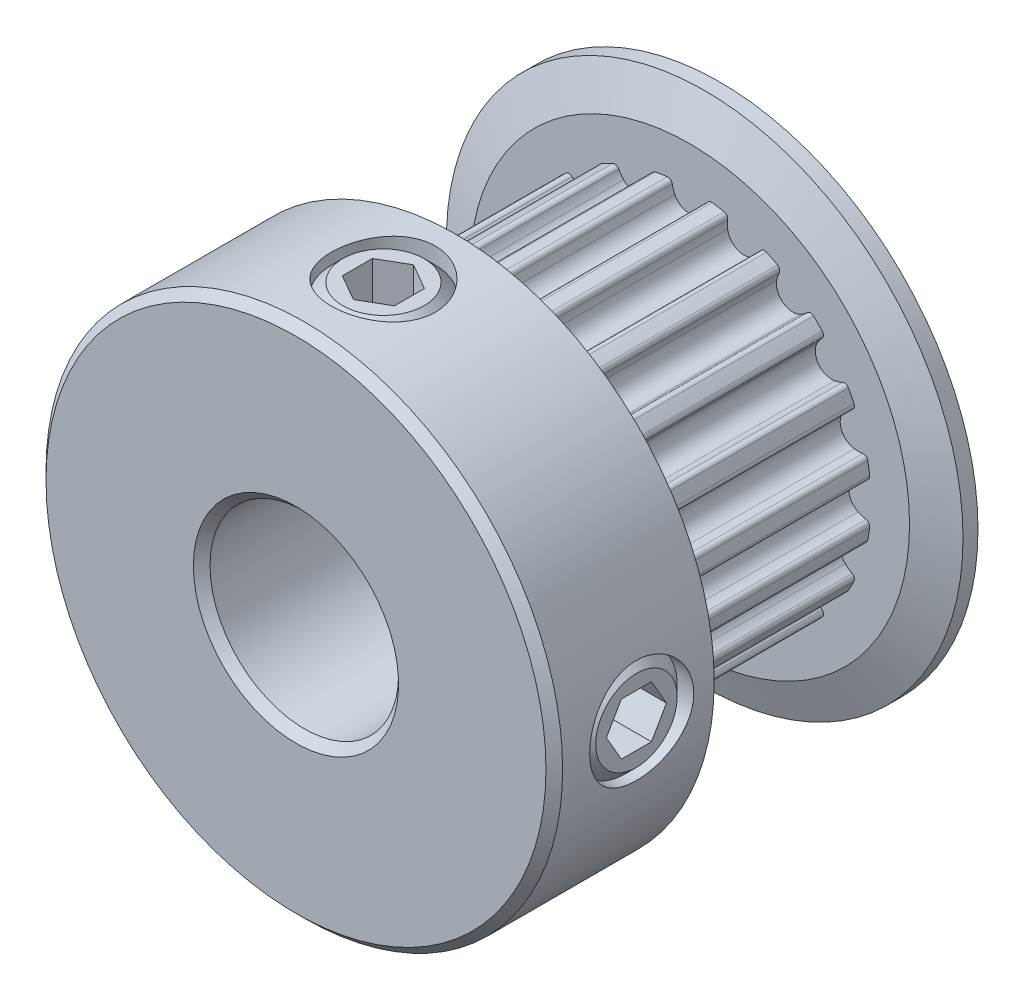
from build123d import *

# Parameters (mm, degrees)
CUT_EXTRUDE1_START = 1.245
CUT_EXTRUDE1_DEPTH = 7.37
CIRPATTERN1_COUNT  = 20
SKETCH4_R          = 1.7526
CUT_EXTRUDE2_DEPTH = 15.22219482
CUT_EXTRUDE3_DEPTH = 1.31445
CIRPATTERN3_COUNT  = 2
CIRPATTERN3_ANGLE  = 90
CHAMFER1_SIZE      = 0.28075


with BuildPart() as part:
    # Sketch2 → Revolve1 (revolve)
    with BuildSketch(Plane(origin=(0, 0, 0), x_dir=(0, 0, -1), z_dir=(1, 0, 0)), mode=Mode.PRIVATE) as revolve1_sk:
        Polygon((-7.135, 3.175), (7.135, 3.175), (7.135, 8.6995), (6.63, 8.6995), (6.125, 7.404), (6.125, 6.1085), (-1.245, 6.1085), (-1.245, 7.404), (-1.75, 8.6995), (-7.135, 8.6995), align=None)
    revolve(revolve1_sk.sketch.rotate(Axis((0, 0, 7.135), (0, 0, -1)), 90), axis=Axis((0, 0, 7.135), (0, 0, -1)))

    # Sketch3 → Cut-Extrude1 (cut)
    with BuildSketch(Plane.XY.offset(CUT_EXTRUDE1_START)):
        with BuildLine():
            Line((2.840989707, 8.6995), (-2.840989707, 8.6995))
            Line((-2.840989707, 8.6995), (-1.896292335, 5.806707124))
            ThreePointArc((-1.896292335, 5.806707124), (-1.330166224, 5.961914966), (-0.751756185, 6.062065233))
            ThreePointArc((-0.751756185, 6.062065233), (-0.643911332, 6.033664451), (-0.58547487, 5.93867868))
            ThreePointArc((-0.58547487, 5.93867868), (-0.551683777, 5.801420225), (-0.498876404, 5.670297753))
            ThreePointArc((-0.498876404, 5.670297753), (0, 5.3585), (0.498876404, 5.670297753))
            ThreePointArc((0.498876404, 5.670297753), (0.551683777, 5.801420225), (0.58547487, 5.93867868))
            ThreePointArc((0.58547487, 5.93867868), (0.643911332, 6.033664451), (0.751756185, 6.062065233))
            ThreePointArc((0.751756185, 6.062065233), (1.330166224, 5.961914966), (1.896292335, 5.806707124))
            Line((1.896292335, 5.806707124), (2.840989707, 8.6995))
        make_face()
    cut_extrude1 = extrude(amount=-CUT_EXTRUDE1_DEPTH, mode=Mode.SUBTRACT)

    # CirPattern1: Cut-Extrude1 ×20 about axis
    cirpattern1_axis = Axis((0, 0, 0), (0, 0, 1))
    for i in range(1, CIRPATTERN1_COUNT):
        add(cut_extrude1.rotate(cirpattern1_axis, i * 360 / CIRPATTERN1_COUNT), mode=Mode.SUBTRACT)

    # Sketch4 → Cut-Extrude2 (cut, through all)
    with BuildSketch(Plane(origin=(0, 0, 0), x_dir=(0, -1, 0), z_dir=(1, 0, 0))):
        with Locations(Location((0, -4.19, 0), (0, 0, 270))):
            Circle(SKETCH4_R)
    cut_extrude2 = extrude(amount=CUT_EXTRUDE2_DEPTH, mode=Mode.SUBTRACT)

    # Sketch5 → Revolve2 (revolve)
    with BuildSketch(Plane.XY.offset(4.19), mode=Mode.PRIVATE) as revolve2_sk:
        Polygon((3.175, -1.3716), (3.175, 0), (8.521132172, 0), (8.521132172, -1.3716), (8.140132172, -1.7526), (3.556, -1.7526), align=None)
    revolve2 = revolve(revolve2_sk.sketch.rotate(Axis((3.175, 0, 4.19), (1, 0, 0)), 270), axis=Axis((3.175, 0, 4.19), (1, 0, 0)))

    # Sketch6 → Cut-Extrude3 (cut)
    with BuildSketch(Plane(origin=(8.521132172, 5.384140679, 0), x_dir=(0, -1, 0), z_dir=(-1, 0, 0))):
        Polygon((5.384140679, 5.201864082), (4.507840679, 4.695932041), (4.507840679, 3.684067959), (5.384140679, 3.178135918), (6.260440679, 3.684067959), (6.260440679, 4.695932041), align=None)
    cut_extrude3 = extrude(amount=CUT_EXTRUDE3_DEPTH, mode=Mode.SUBTRACT)

    # CirPattern3: Cut-Extrude2, Revolve2, Cut-Extrude3 ×2 about axis
    cirpattern3_axis = Axis((0, 0, 0), (0, 0, 1))
    add([cut_extrude2.rotate(cirpattern3_axis, i * CIRPATTERN3_ANGLE / (CIRPATTERN3_COUNT - 1)) for i in range(1, CIRPATTERN3_COUNT)], mode=Mode.SUBTRACT)
    add([revolve2.rotate(cirpattern3_axis, i * CIRPATTERN3_ANGLE / (CIRPATTERN3_COUNT - 1)) for i in range(1, CIRPATTERN3_COUNT)])
    add([cut_extrude3.rotate(cirpattern3_axis, i * CIRPATTERN3_ANGLE / (CIRPATTERN3_COUNT - 1)) for i in range(1, CIRPATTERN3_COUNT)], mode=Mode.SUBTRACT)

    # Chamfer1
    chamfer1_edges = [part.edges().sort_by_distance(p)[0] for p in [
        (-3.175, 0, 7.135),
        (-8.6995, 0, 7.135),
    ]]
    chamfer(chamfer1_edges, length=CHAMFER1_SIZE)


solid = part.part
